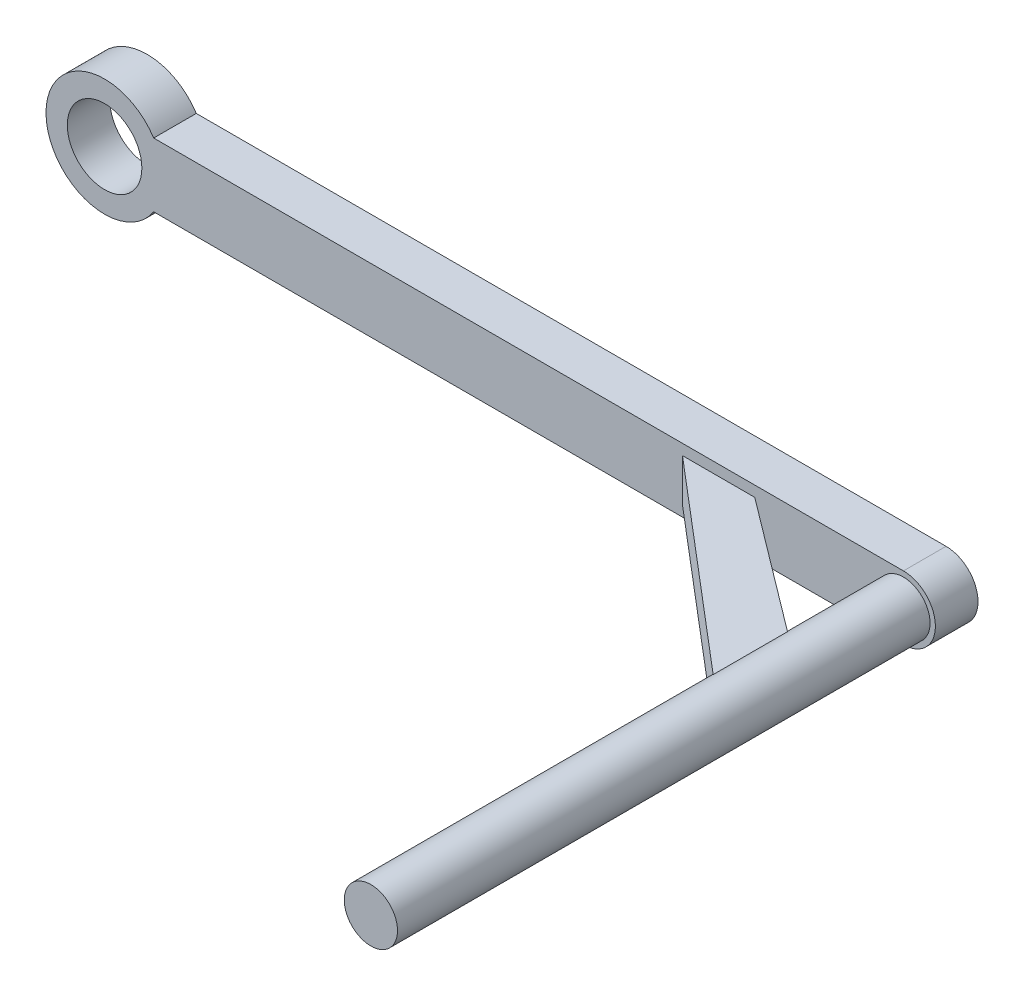
from build123d import *

# Parameters (mm, degrees)
SKETCH1_R                = 3.5
BOSS_EXTRUDE1_DEPTH      = 4
SKETCH2_R                = 2.5
BOSS_EXTRUDE2_DEPTH      = 50
BOSS_EXTRUDE3_DEPTH      = 2
BOSS_EXTRUDE3_DEPTH_BACK = 2


with BuildPart() as part:
    # Sketch1 → Boss-Extrude1 (new body)
    with BuildSketch(Plane.XY):
        with BuildLine():
            Line((0, -3), (-70.390227771, -3))
            ThreePointArc((-70.390227771, -3), (-80.5, 0), (-70.390227771, 3))
            Line((-70.390227771, 3), (0, 3))
            ThreePointArc((0, 3), (3, 0), (0, -3))
        make_face()
        with Locations((-75, 0)):
            Circle(SKETCH1_R, mode=Mode.SUBTRACT)
    extrude(amount=BOSS_EXTRUDE1_DEPTH)

    # Sketch2 → Boss-Extrude2 (add)
    with BuildSketch(Plane.XY.offset(4)):
        Circle(SKETCH2_R)
    extrude(amount=BOSS_EXTRUDE2_DEPTH)

    # Sketch3 → Boss-Extrude3 (add, two sides)
    with BuildSketch(Plane(origin=(0, 0, 0), x_dir=(1, 0, 0), z_dir=(0, 1, 0))) as boss_extrude3_sk:
        Polygon((-22.626919406, -2.400081024), (-16.082292112, -2.400081024), (0, -14.514826908), (0, -21.639035848), align=None)
    extrude(amount=BOSS_EXTRUDE3_DEPTH)
    extrude(boss_extrude3_sk.sketch, amount=-BOSS_EXTRUDE3_DEPTH_BACK)


solid = part.part
